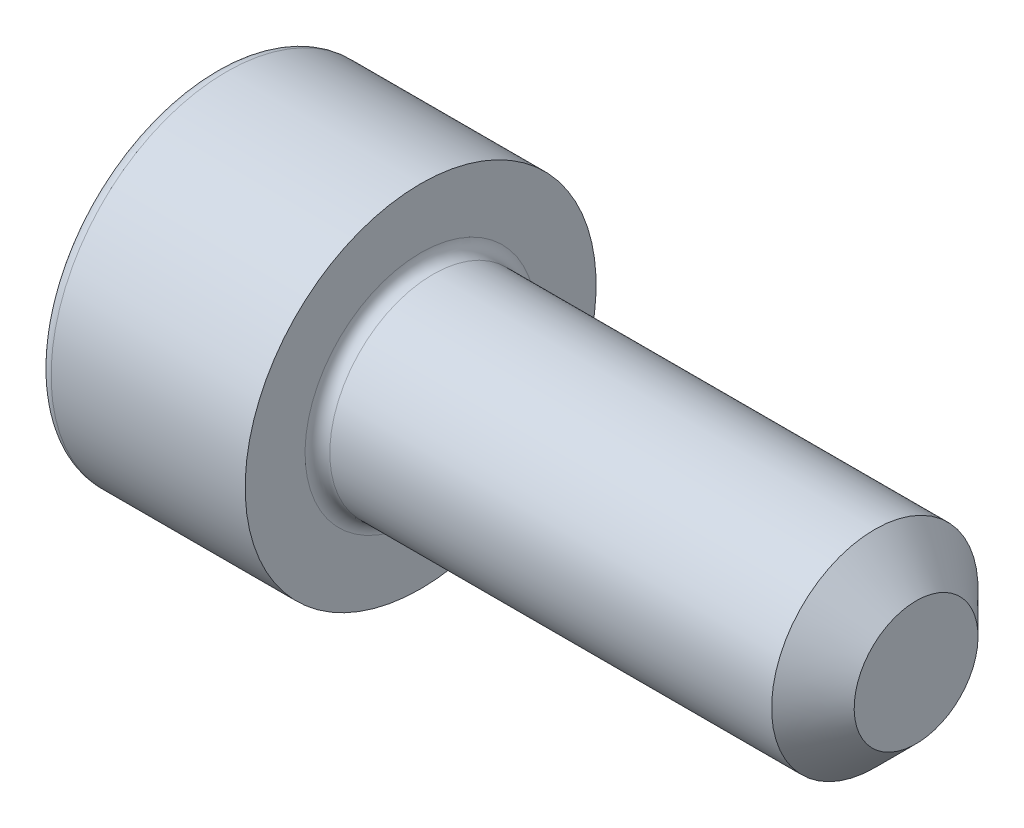
from build123d import *

# Parameters (mm, degrees)
CUT_EXTRUDE_1_DEPTH = 2.5
FILLET_1_R          = 0.3
CHAMFER_1_SIZE      = 1


with BuildPart() as part:
    # Эскиз1 → Повернуть1 (revolve)
    with BuildSketch(Plane.XY):
        Polygon((0, 0), (0, 4.25), (5, 4.25), (5, 2.5), (17, 2.5), (17, 0), align=None)
    revolve(axis=Axis((17, 0, 0), (-1, 0, 0)))

    # Эскиз2 → Вырез-Вытянуть1 (cut)
    with BuildSketch(Plane.ZY):
        Polygon((-1.154700538, 2), (-2.309401077, 0), (-1.154700538, -2), (1.154700538, -2), (2.309401077, 0), (1.154700538, 2), align=None)
    extrude(amount=-CUT_EXTRUDE_1_DEPTH, mode=Mode.SUBTRACT)

    # Скругление1
    fillet_1_edges = [part.edges().sort_by_distance(p)[0] for p in [
        (5, -2.5, 0),
        (0, -4.25, 0),
    ]]
    fillet(fillet_1_edges, radius=FILLET_1_R)

    # Фаска1
    chamfer_1_edges = [part.edges().sort_by_distance(p)[0] for p in [
        (17, -2.5, 0),
    ]]
    chamfer(chamfer_1_edges, length=CHAMFER_1_SIZE)


solid = part.part
